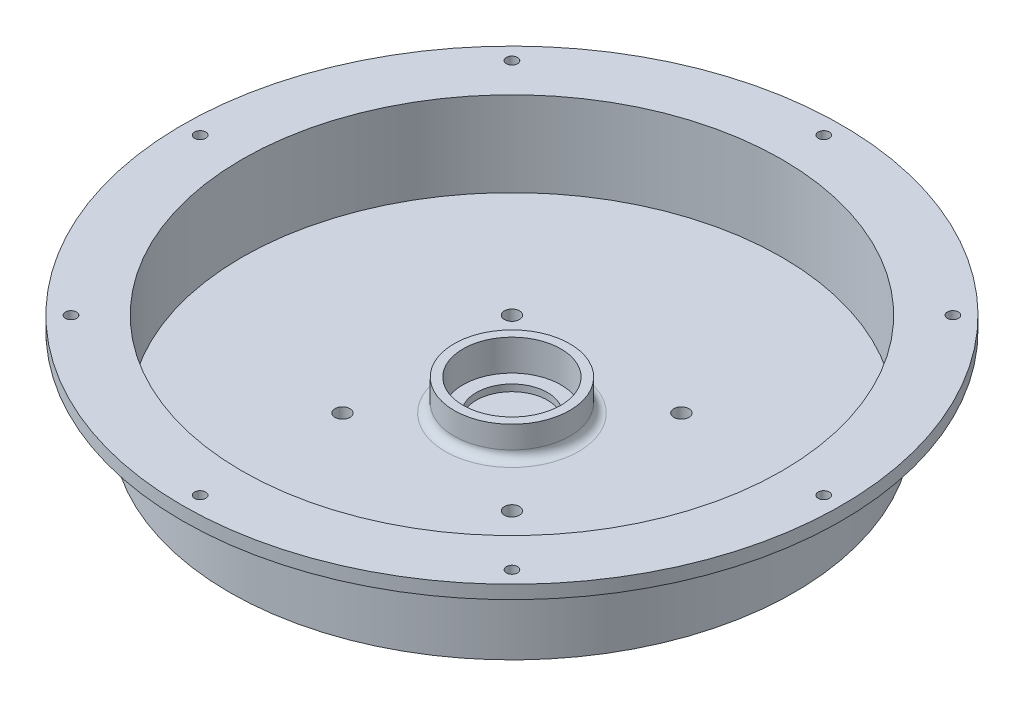
from build123d import *

# Parameters (mm, degrees)
SKETCH1_R             = 63.5
SKETCH1_R_2           = 60.690000065
BOSS_EXTRUDE1_DEPTH   = 22.225
SKETCH3_R             = 63.5
BOSS_EXTRUDE2_DEPTH   = 3.175
SKETCH8_R             = 13
SKETCH8_R_2           = 11
BOSS_EXTRUDE4_DEPTH   = 7
SKETCH10_R            = 74.095000033
SKETCH10_R_2          = 63.5
BOSS_EXTRUDE5_DEPTH   = 3
M3X0_5_TAPPED_HOLE1_D = 2.5
CIRPATTERN2_COUNT     = 8
SKETCH16_R            = 8
CUT_EXTRUDE1_DEPTH    = 1.5
FILLET1_R             = 2
FILLET2_R             = 3
SKETCH19_R            = 1.7
CUT_EXTRUDE2_DEPTH    = 4.175


with BuildPart() as part:
    # Sketch1 → Boss-Extrude1 (new body)
    with BuildSketch(Plane(origin=(0, 0, 0), x_dir=(1, 0, 0), z_dir=(0, 1, 0))):
        Circle(SKETCH1_R)
        Circle(SKETCH1_R_2, mode=Mode.SUBTRACT)
    extrude(amount=BOSS_EXTRUDE1_DEPTH)

    # Sketch3 → Boss-Extrude2 (add)
    with BuildSketch(Plane(origin=(0, 0, 0), x_dir=(1, 0, 0), z_dir=(0, 1, 0))):
        Circle(SKETCH3_R)
    extrude(amount=BOSS_EXTRUDE2_DEPTH)

    # Sketch8 → Boss-Extrude4 (add)
    with BuildSketch(Plane(origin=(0, 3.175, 0), x_dir=(1, 0, 0), z_dir=(0, 1, 0))):
        Circle(SKETCH8_R)
        Circle(SKETCH8_R_2, mode=Mode.SUBTRACT)
    extrude(amount=BOSS_EXTRUDE4_DEPTH)

    # Sketch10 → Boss-Extrude5 (add)
    with BuildSketch(Plane(origin=(0, 22.225, 0), x_dir=(1, 0, 0), z_dir=(0, 1, 0))):
        Circle(SKETCH10_R)
        Circle(SKETCH10_R_2, mode=Mode.SUBTRACT)
    extrude(amount=-BOSS_EXTRUDE5_DEPTH)

    # M3x0.5 Tapped Hole1 (through all)
    with Locations(Plane(origin=(0, 22.225, 0), x_dir=(1, 0, 0), z_dir=(0, 1, 0))):
        with Locations((-70.1, 0)):
            m3x0_5_tapped_hole1 = Hole(M3X0_5_TAPPED_HOLE1_D / 2)

    # CirPattern2: M3x0.5 Tapped Hole1 ×8 about axis
    cirpattern2_axis = Axis((0, 0, 0), (0, 1, 0))
    for i in range(1, CIRPATTERN2_COUNT):
        add(m3x0_5_tapped_hole1.rotate(cirpattern2_axis, i * 360 / CIRPATTERN2_COUNT), mode=Mode.SUBTRACT)

    # Sketch16 → Cut-Extrude1 (cut)
    with BuildSketch(Plane(origin=(0, 3.175, 0), x_dir=(1, 0, 0), z_dir=(0, 1, 0))):
        Circle(SKETCH16_R)
    extrude(amount=-CUT_EXTRUDE1_DEPTH, mode=Mode.SUBTRACT)

    # Fillet1
    fillet1_edges = [part.edges().sort_by_distance(p)[0] for p in [
        (-13, 3.175, 0),
    ]]
    fillet(fillet1_edges, radius=FILLET1_R)

    # Fillet2
    fillet2_edges = [part.edges().sort_by_distance(p)[0] for p in [
        (-63.5, 19.225, 0),
    ]]
    fillet(fillet2_edges, radius=FILLET2_R)

    # Sketch19 → Cut-Extrude2 (cut, through all)
    with BuildSketch(Plane(origin=(0, 3.175, 0), x_dir=(1, 0, 0), z_dir=(0, 1, 0))):
        with Locations((19.05, -19.05)):
            Circle(SKETCH19_R)
        with Locations((19.05, 19.05)):
            Circle(SKETCH19_R)
        with Locations((-19.05, -19.05)):
            Circle(SKETCH19_R)
        with Locations((-19.05, 19.05)):
            Circle(SKETCH19_R)
    extrude(amount=-CUT_EXTRUDE2_DEPTH, mode=Mode.SUBTRACT)


solid = part.part
